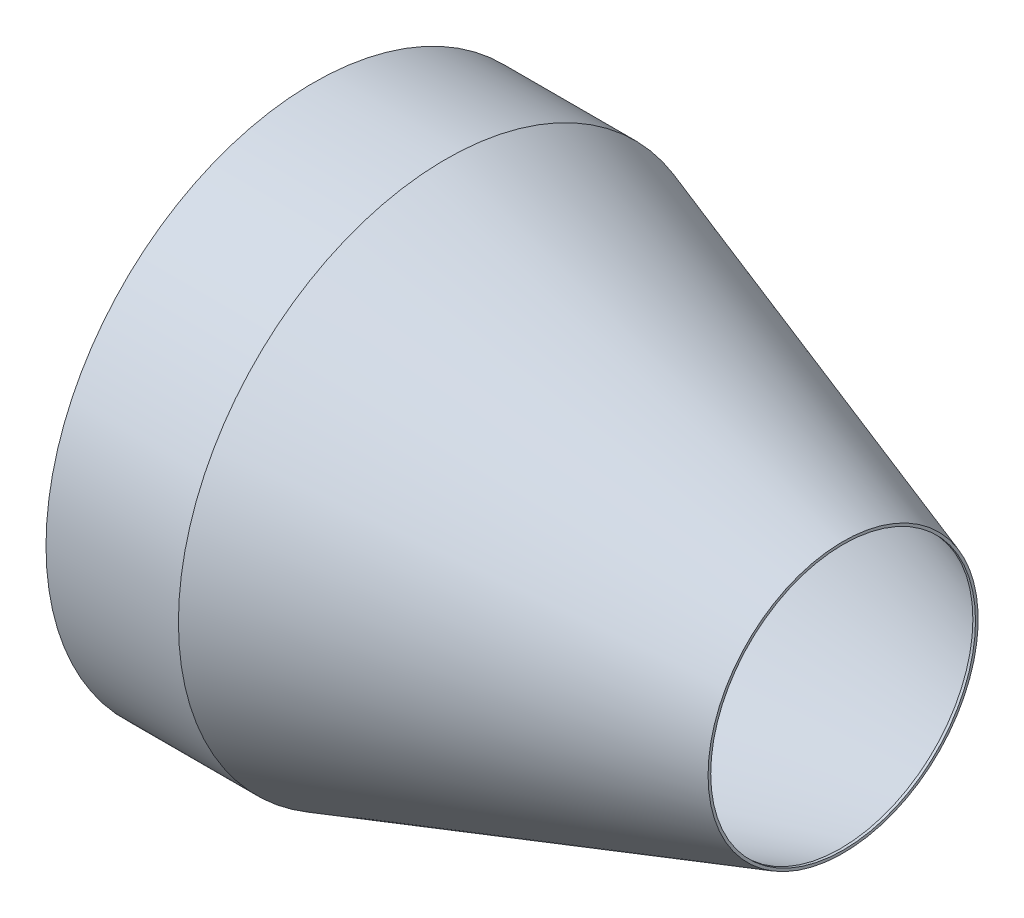
from build123d import *

# Parameters (mm, degrees)
SKETCH2_R          = 50
CUT_EXTRUDE1_DEPTH = 10
SKETCH3_R          = 1
CUT_EXTRUDE2_DEPTH = 180
SKETCH4_R          = 1
CUT_EXTRUDE3_DEPTH = 1
SKETCH5_R          = 99.5
CUT_EXTRUDE7_DEPTH = 26


with BuildPart() as part:
    # Sketch1 → Revolve1 (revolve)
    with BuildSketch(Plane.XY):
        Polygon((0, 0), (50, 0), (200, 50), (200, 101), (0, 101), align=None)
        Polygon((49.83772234, 1), (199, 50.72075922), (199, 100), (1, 100), (1, 1), align=None, mode=Mode.SUBTRACT)
    revolve(axis=Axis((0, 101, 0), (1, 0, 0)))

    # Sketch2 → Cut-Extrude1 (cut)
    with BuildSketch(Plane(origin=(200, 0, 0), x_dir=(0, 0, -1), z_dir=(1, 0, 0))):
        with Locations((0, 101)):
            Circle(SKETCH2_R)
    extrude(amount=-CUT_EXTRUDE1_DEPTH, mode=Mode.SUBTRACT)

    # Sketch3 → Cut-Extrude2 (cut)
    with BuildSketch(Plane(origin=(190, 0, 0), x_dir=(0, 0, -1), z_dir=(1, 0, 0))):
        with Locations((0, 101)):
            Circle(SKETCH3_R)
    extrude(amount=-CUT_EXTRUDE2_DEPTH, mode=Mode.SUBTRACT)

    # Sketch4 → Cut-Extrude3 (cut)
    with BuildSketch(Plane(origin=(10, 0, 0), x_dir=(0, 0, -1), z_dir=(1, 0, 0))):
        with Locations((0, 101)):
            Circle(SKETCH4_R)
    extrude(amount=-CUT_EXTRUDE3_DEPTH, mode=Mode.SUBTRACT)

    # Sketch5 → Cut-Extrude7 (cut)
    with BuildSketch(Plane.ZY):
        with Locations((0, 101)):
            Circle(SKETCH5_R)
    extrude(amount=-CUT_EXTRUDE7_DEPTH, mode=Mode.SUBTRACT)


solid = part.part
